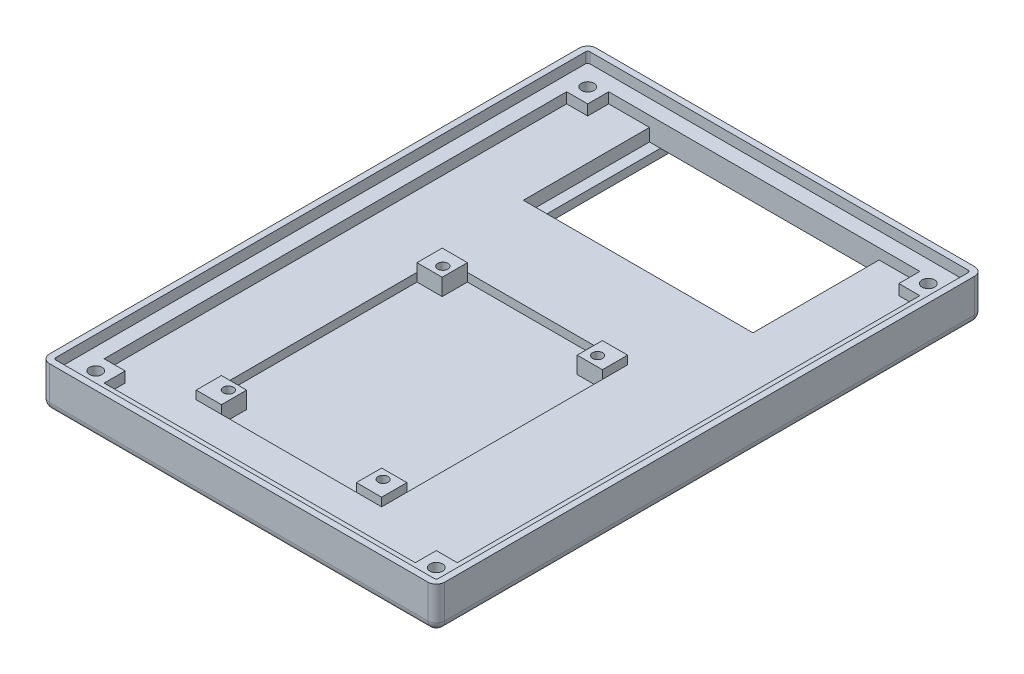
from build123d import *

# Parameters (mm, degrees)
SKETCH1_W           = 94
SKETCH1_H           = 130
BOSS_EXTRUDE1_DEPTH = 5
SKETCH2_W           = 94
SKETCH2_H           = 130
SKETCH2_W_2         = 84
SKETCH2_H_2         = 120
BOSS_EXTRUDE2_DEPTH = 5
FILLET1_R           = 2
SKETCH3_W           = 44.1
SKETCH3_H           = 58.5
CUT_EXTRUDE1_DEPTH  = 2
SKETCH5_W           = 6
SKETCH5_H           = 6
BOSS_EXTRUDE4_DEPTH = 4
SKETCH7_R           = 1.20000014
CUT_EXTRUDE2_DEPTH  = 3
SKETCH8_W           = 54.6
SKETCH8_H           = 30
CUT_EXTRUDE3_DEPTH  = 3
SKETCH9_W           = 49.4
SKETCH9_H           = 27
CUT_EXTRUDE4_DEPTH  = 2
SKETCH10_W          = 49.4
SKETCH10_H          = 6.619549161
CUT_EXTRUDE5_DEPTH  = 2
SKETCH11_W          = 5
SKETCH11_H          = 1
CUT_EXTRUDE6_DEPTH  = 3
SKETCH14_W          = 84
SKETCH14_H          = 120
CUT_EXTRUDE8_DEPTH  = 2.5
SKETCH15_W          = 5
SKETCH15_H          = 5
BOSS_EXTRUDE5_DEPTH = 2.5
SKETCH16_R          = 1.5
CUT_EXTRUDE9_DEPTH  = 8.5
SKETCH17_R          = 2.8
CUT_EXTRUDE10_DEPTH = 3
SKETCH18_R          = 4
CUT_EXTRUDE11_DEPTH = 2


with BuildPart() as part:
    # Sketch1 → Boss-Extrude1 (new body)
    with BuildSketch(Plane(origin=(0, 0, 0), x_dir=(1, 0, 0), z_dir=(0, 1, 0))):
        with Locations((47, 65)):
            Rectangle(SKETCH1_W, SKETCH1_H)
    extrude(amount=BOSS_EXTRUDE1_DEPTH)

    # Sketch2 → Boss-Extrude2 (add)
    with BuildSketch(Plane(origin=(0, 5, 0), x_dir=(1, 0, 0), z_dir=(0, 1, 0))):
        with Locations((47, 65)):
            Rectangle(SKETCH2_W, SKETCH2_H)
        with Locations((47, 65)):
            Rectangle(SKETCH2_W_2, SKETCH2_H_2, mode=Mode.SUBTRACT)
    extrude(amount=BOSS_EXTRUDE2_DEPTH)

    # Fillet1
    fillet1_edges = [part.edges().sort_by_distance(p)[0] for p in [
        (47, 0, -130),
        (94, 0, -65),
        (47, 0, 0),
        (0, 0, -65),
        (0, 5, -130),
        (94, 5, -130),
        (94, 5, 0),
        (0, 5, 0),
    ]]
    fillet(fillet1_edges, radius=FILLET1_R)

    # Sketch3 → Cut-Extrude1 (cut)
    with BuildSketch(Plane(origin=(0, 5, 0), x_dir=(1, 0, 0), z_dir=(0, 1, 0))):
        with Locations((43.95, 44.25)):
            Rectangle(SKETCH3_W, SKETCH3_H)
    extrude(amount=-CUT_EXTRUDE1_DEPTH, mode=Mode.SUBTRACT)

    # Sketch5 → Boss-Extrude4 (add)
    with BuildSketch(Plane(origin=(0, 3, 0), x_dir=(1, 0, 0), z_dir=(0, 1, 0))):
        with Locations((24.9, 70.5)):
            Rectangle(SKETCH5_W, SKETCH5_H)
        with Locations((63, 70.5)):
            Rectangle(SKETCH5_W, SKETCH5_H)
        with Locations((63, 18)):
            Rectangle(SKETCH5_W, SKETCH5_H)
        with Locations((24.9, 18)):
            Rectangle(SKETCH5_W, SKETCH5_H)
    extrude(amount=BOSS_EXTRUDE4_DEPTH)

    # Sketch7 → Cut-Extrude2 (cut)
    with BuildSketch(Plane(origin=(0, 7, 0), x_dir=(1, 0, 0), z_dir=(0, 1, 0))):
        with Locations((25.710000549, 69.839000092)):
            Circle(SKETCH7_R)
        with Locations((62.514600549, 69.839000092)):
            Circle(SKETCH7_R)
        with Locations((62.514600549, 18.835800092)):
            Circle(SKETCH7_R)
        with Locations((25.710000549, 18.835800092)):
            Circle(SKETCH7_R)
    extrude(amount=-CUT_EXTRUDE2_DEPTH, mode=Mode.SUBTRACT)

    # Sketch8 → Cut-Extrude3 (cut)
    with BuildSketch(Plane(origin=(0, 5, 0), x_dir=(1, 0, 0), z_dir=(0, 1, 0))):
        with Locations((47, 110)):
            Rectangle(SKETCH8_W, SKETCH8_H)
    extrude(amount=-CUT_EXTRUDE3_DEPTH, mode=Mode.SUBTRACT)

    # Sketch9 → Cut-Extrude4 (cut)
    with BuildSketch(Plane(origin=(0, 2, 0), x_dir=(1, 0, 0), z_dir=(0, 1, 0))):
        with Locations((47, 110)):
            Rectangle(SKETCH9_W, SKETCH9_H)
    extrude(amount=-CUT_EXTRUDE4_DEPTH, mode=Mode.SUBTRACT)

    # Sketch10 → Cut-Extrude5 (cut)
    with BuildSketch(Plane.XZ):
        with Locations((47, -126.809774581)):
            Rectangle(SKETCH10_W, SKETCH10_H)
    extrude(amount=-CUT_EXTRUDE5_DEPTH, mode=Mode.SUBTRACT)

    # Sketch11 → Cut-Extrude6 (cut)
    with BuildSketch(Plane(origin=(0, 0, -96.5), x_dir=(-1, 0, 0), z_dir=(0, 0, -1))):
        with Locations((-47, 1)):
            Rectangle(SKETCH11_W, SKETCH11_H)
    extrude(amount=-CUT_EXTRUDE6_DEPTH, mode=Mode.SUBTRACT)

    # Sketch14 → Cut-Extrude8 (cut)
    with BuildSketch(Plane(origin=(0, 10, 0), x_dir=(1, 0, 0), z_dir=(0, 1, 0))):
        with BuildLine():
            Line((92.5, 2), (92.5, 128))
            ThreePointArc((92.5, 128), (92.353553391, 128.353553391), (92, 128.5))
            Line((92, 128.5), (2, 128.5))
            ThreePointArc((2, 128.5), (1.646446609, 128.353553391), (1.5, 128))
            Line((1.5, 128), (1.5, 2))
            ThreePointArc((1.5, 2), (1.646446609, 1.646446609), (2, 1.5))
            Line((2, 1.5), (92, 1.5))
            ThreePointArc((92, 1.5), (92.353553391, 1.646446609), (92.5, 2))
        make_face()
        with Locations((47, 65)):
            Rectangle(SKETCH14_W, SKETCH14_H, mode=Mode.SUBTRACT)
    extrude(amount=-CUT_EXTRUDE8_DEPTH, mode=Mode.SUBTRACT)

    # Sketch15 → Boss-Extrude5 (add)
    with BuildSketch(Plane(origin=(0, 5, 0), x_dir=(1, 0, 0), z_dir=(0, 1, 0))):
        with Locations((86.5, 122.5)):
            Rectangle(SKETCH15_W, SKETCH15_H)
        with Locations((7.5, 122.5)):
            Rectangle(SKETCH15_W, SKETCH15_H)
        with Locations((7.5, 7.5)):
            Rectangle(SKETCH15_W, SKETCH15_H)
        with Locations((86.5, 7.5)):
            Rectangle(SKETCH15_W, SKETCH15_H)
    extrude(amount=BOSS_EXTRUDE5_DEPTH)

    # Sketch16 → Cut-Extrude9 (cut, through all)
    with BuildSketch(Plane(origin=(0, 7.5, 0), x_dir=(1, 0, 0), z_dir=(0, 1, 0))):
        with Locations((6.5, 123.5)):
            Circle(SKETCH16_R)
        with Locations((87.5, 123.5)):
            Circle(SKETCH16_R)
        with Locations((87.5, 6.5)):
            Circle(SKETCH16_R)
        with Locations((6.5, 6.5)):
            Circle(SKETCH16_R)
    extrude(amount=-CUT_EXTRUDE9_DEPTH, mode=Mode.SUBTRACT)

    # Sketch17 → Cut-Extrude10 (cut)
    with BuildSketch(Plane.XZ):
        with Locations((6.5, -6.5)):
            Circle(SKETCH17_R)
        with Locations((87.5, -6.5)):
            Circle(SKETCH17_R)
        with Locations((87.5, -123.5)):
            Circle(SKETCH17_R)
        with Locations((6.5, -123.5)):
            Circle(SKETCH17_R)
    extrude(amount=-CUT_EXTRUDE10_DEPTH, mode=Mode.SUBTRACT)

    # Sketch18 → Cut-Extrude11 (cut)
    with BuildSketch(Plane.XZ):
        with Locations((6.5, -123.5)):
            Circle(SKETCH18_R)
        with Locations((87.5, -123.5)):
            Circle(SKETCH18_R)
        with Locations((87.5, -6.5)):
            Circle(SKETCH18_R)
        with Locations((6.5, -6.5)):
            Circle(SKETCH18_R)
    extrude(amount=-CUT_EXTRUDE11_DEPTH, mode=Mode.SUBTRACT)


solid = part.part
